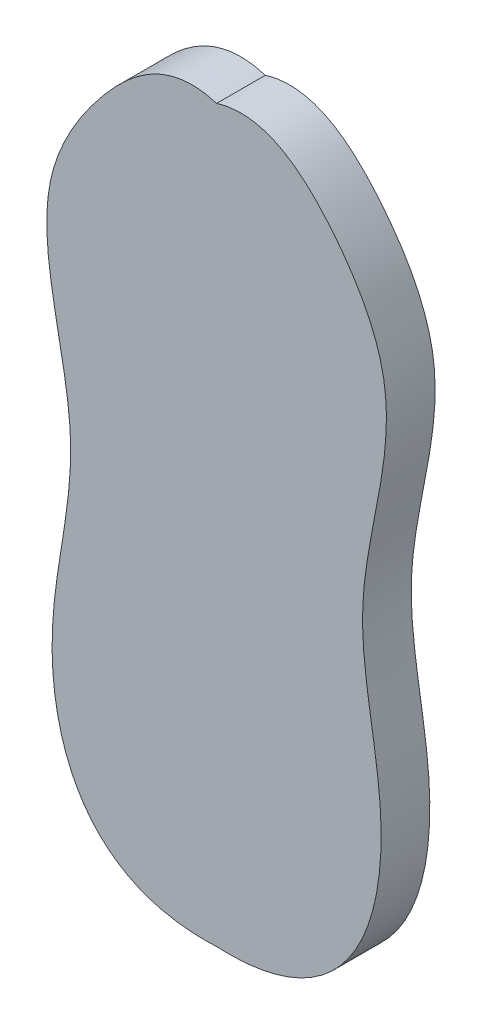
from build123d import *

# Parameters (mm, degrees)
BOSS_EXTRUDE1_DEPTH = 10


with BuildPart() as part:
    # Sketch2 → Boss-Extrude1 (new body)
    with BuildSketch(Plane.XY):
        with BuildLine():
            add(Edge.make_bspline(
                [(0, 99.183285394), (9.940064442, 102.262299521), (24.122612265, 90.46414584), (40.33453266, 61.943212567), (25.180027607, 26.436288764), (39.04722634, -17.717188406), (27.280230095, -52.099061458), (0, -50.816714606)],
                knots=[0, 0, 0, 0, 0.146529274, 0.268876507, 0.503259797, 0.694010191, 1, 1, 1, 1], degree=3))
            add(Edge.make_bspline(
                [(0, 99.183285394), (-9.940064442, 102.262299521), (-24.122612265, 90.46414584), (-40.33453266, 61.943212567), (-25.180027607, 26.436288764), (-39.04722634, -17.717188406), (-27.280230095, -52.099061458), (0, -50.816714606)],
                knots=[0, 0, 0, 0, 0.146529274, 0.268876507, 0.503259797, 0.694010191, 1, 1, 1, 1], degree=3))
        make_face()
    extrude(amount=BOSS_EXTRUDE1_DEPTH)


solid = part.part
